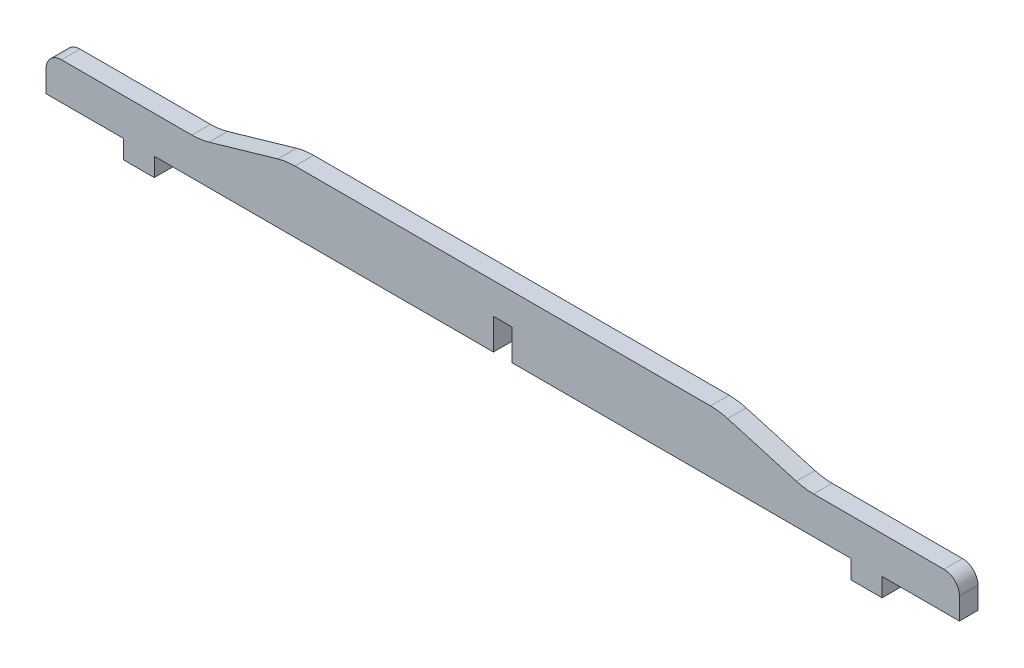
from build123d import *

# Parameters (mm, degrees)
BOSS_EXTRUDE1_DEPTH     = 6
FILLET1_R               = 5
FILLET2_R               = 20
SKETCH2_W               = 6
SKETCH2_H               = 10
CUT_EXTRUDE1_DEPTH      = 1
CUT_EXTRUDE1_DEPTH_BACK = 7


with BuildPart() as part:
    # Sketch1 → Boss-Extrude1 (new body)
    with BuildSketch(Plane.XY):
        Polygon((70, 0), (-70, 0), (-97.66666667, -8), (-147.66666667, -8), (-147.66666667, -20), (-122.66666667, -20), (-122.66666667, -26), (-112.66666667, -26), (-112.66666667, -20), (112.66666667, -20), (112.66666667, -26), (122.66666667, -26), (122.66666667, -20), (147.66666667, -20), (147.66666667, -8), (97.66666667, -8), align=None)
    extrude(amount=BOSS_EXTRUDE1_DEPTH)

    # Fillet1
    fillet1_edges = [part.edges().sort_by_distance(p)[0] for p in [
        (-147.66666667, -8, 3),
        (147.66666667, -8, 3),
    ]]
    fillet(fillet1_edges, radius=FILLET1_R)

    # Fillet2
    fillet2_edges = [part.edges().sort_by_distance(p)[0] for p in [
        (-97.66666667, -8, 3),
        (-70, 0, 3),
        (70, 0, 3),
        (97.66666667, -8, 3),
    ]]
    fillet(fillet2_edges, radius=FILLET2_R)

    # Sketch2 → Cut-Extrude1 (cut, two sides)
    with BuildSketch(Plane.XY.offset(6)) as cut_extrude1_sk:
        with Locations((0, -15)):
            Rectangle(SKETCH2_W, SKETCH2_H)
    extrude(amount=CUT_EXTRUDE1_DEPTH, mode=Mode.SUBTRACT)
    extrude(cut_extrude1_sk.sketch, amount=-CUT_EXTRUDE1_DEPTH_BACK, mode=Mode.SUBTRACT)


solid = part.part
